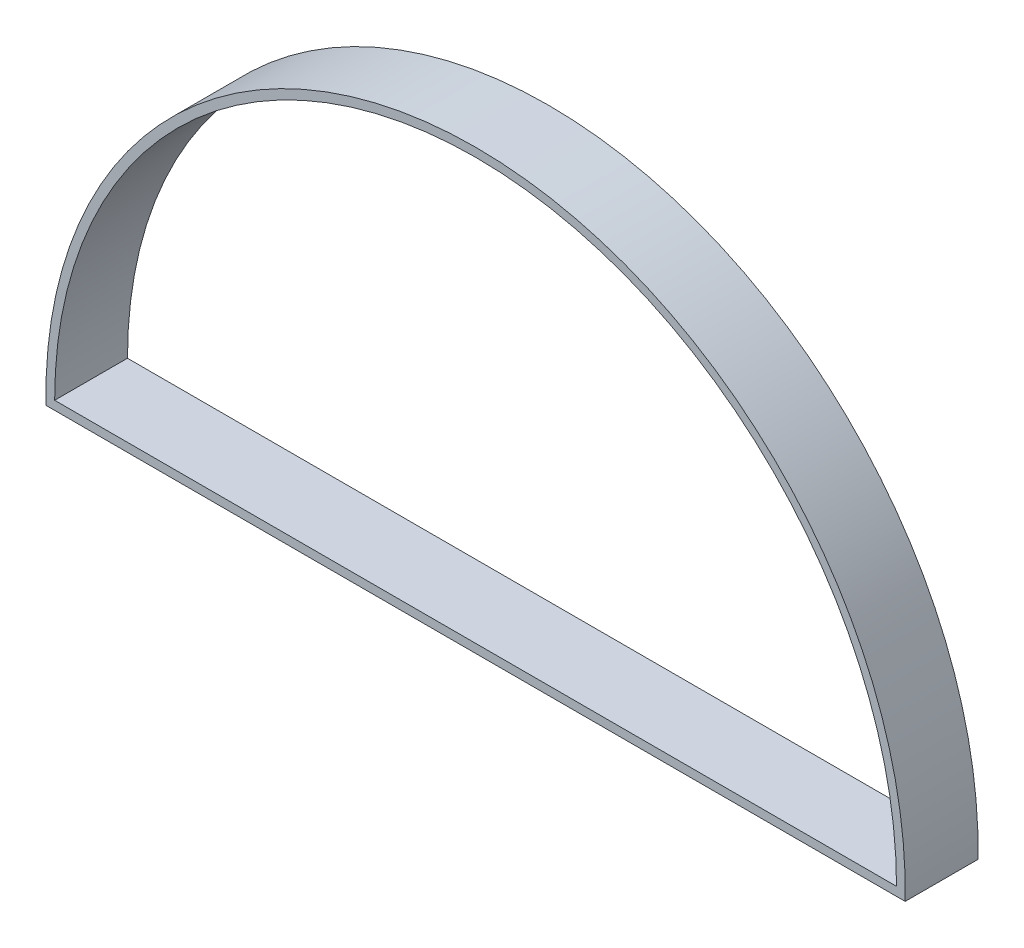
from build123d import *

# Parameters (mm, degrees)
EXTRU_MINCE1_DEPTH = 25


with BuildPart() as part:
    # Esquisse1 → Extru.-Mince1 (new body)
    with BuildSketch(Plane.XY):
        with BuildLine():
            Line((-2.96948837, -3), (246, -3))
            Line((246, -3), (291.96948837, -3))
            ThreePointArc((291.96948837, -3), (144.5, 147.5), (-2.96948837, -3))
        make_face()
        with BuildLine():
            Line((0, 0), (246, 0))
            Line((246, 0), (289, 0))
            ThreePointArc((289, 0), (144.5, 144.5), (0, 0))
        make_face(mode=Mode.SUBTRACT)
    extrude(amount=EXTRU_MINCE1_DEPTH)


solid = part.part
